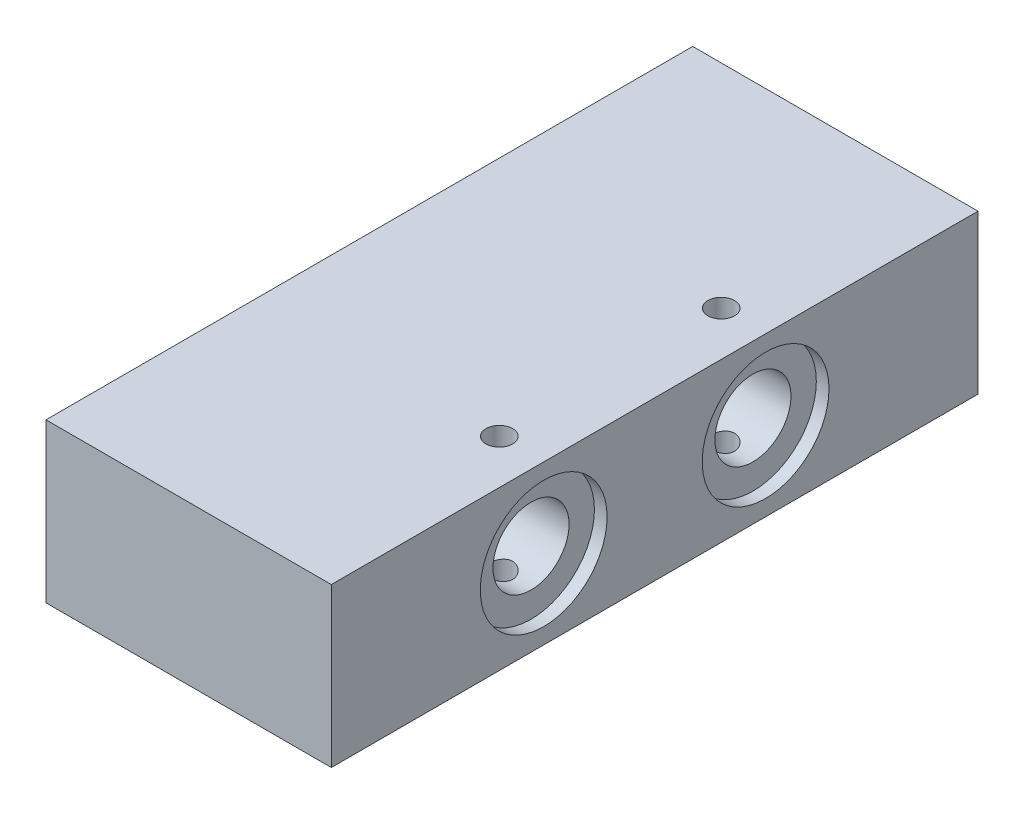
from build123d import *

# Parameters (mm, degrees)
SKETCH1_W             = 45
SKETCH1_H             = 102
BOSS_EXTRUDE1_DEPTH   = 25
M5_TAPPED_HOLE3_D     = 4.2
SKETCH27_R            = 6
CUT_EXTRUDE1_DEPTH    = 74
SKETCH28_R            = 10
CUT_EXTRUDE3_DEPTH    = 2
SKETCH30_R            = 10
CUT_EXTRUDE4_DEPTH    = 2
M5_TAPPED_HOLE4_D     = 4.2
M5_TAPPED_HOLE4_DEPTH = 14
M5_TAPPED_HOLE4_TIP   = 1.2618073


with BuildPart() as part:
    # Sketch1 → Boss-Extrude1 (new body)
    with BuildSketch(Plane(origin=(0, 0, 0), x_dir=(1, 0, 0), z_dir=(0, 1, 0))):
        Rectangle(SKETCH1_W, SKETCH1_H)
    extrude(amount=BOSS_EXTRUDE1_DEPTH)

    # M5 Tapped Hole3 (through all)
    with Locations(Plane(origin=(0, 25, 0), x_dir=(1, 0, 0), z_dir=(0, 1, 0))):
        with Locations((15.5, 17.5), (15.5, -17.5)):
            Hole(M5_TAPPED_HOLE3_D / 2)

    # Sketch27 → Cut-Extrude1 (cut)
    with BuildSketch(Plane.ZY.offset(22.5)):
        with Locations((-17.5, 12.5)):
            Circle(SKETCH27_R)
        with Locations((17.5, 12.5)):
            Circle(SKETCH27_R)
    extrude(amount=-CUT_EXTRUDE1_DEPTH, mode=Mode.SUBTRACT)

    # Sketch28 → Cut-Extrude3 (cut)
    with BuildSketch(Plane.ZY.offset(22.5)):
        with Locations((-17.5, 12.5)):
            Circle(SKETCH28_R)
        with Locations((17.5, 12.5)):
            Circle(SKETCH28_R)
    extrude(amount=-CUT_EXTRUDE3_DEPTH, mode=Mode.SUBTRACT)

    # Sketch30 → Cut-Extrude4 (cut)
    with BuildSketch(Plane(origin=(22.5, 0, 0), x_dir=(0, 0, -1), z_dir=(1, 0, 0))):
        with Locations((-17.5, 12.5)):
            Circle(SKETCH30_R)
        with Locations((17.5, 12.5)):
            Circle(SKETCH30_R)
    extrude(amount=-CUT_EXTRUDE4_DEPTH, mode=Mode.SUBTRACT)

    # M5 Tapped Hole4
    with Locations(Plane(origin=(0, 0, -51), x_dir=(-1, 0, 0), z_dir=(0, 0, -1))):
        with Locations((-18, 5), (18, 20)):
            Hole(M5_TAPPED_HOLE4_D / 2, depth=M5_TAPPED_HOLE4_DEPTH)
            with Locations((0, 0, -(M5_TAPPED_HOLE4_DEPTH + M5_TAPPED_HOLE4_TIP / 2))):  # 118° drill point
                Cone(0, M5_TAPPED_HOLE4_D / 2, M5_TAPPED_HOLE4_TIP, mode=Mode.SUBTRACT)


solid = part.part
